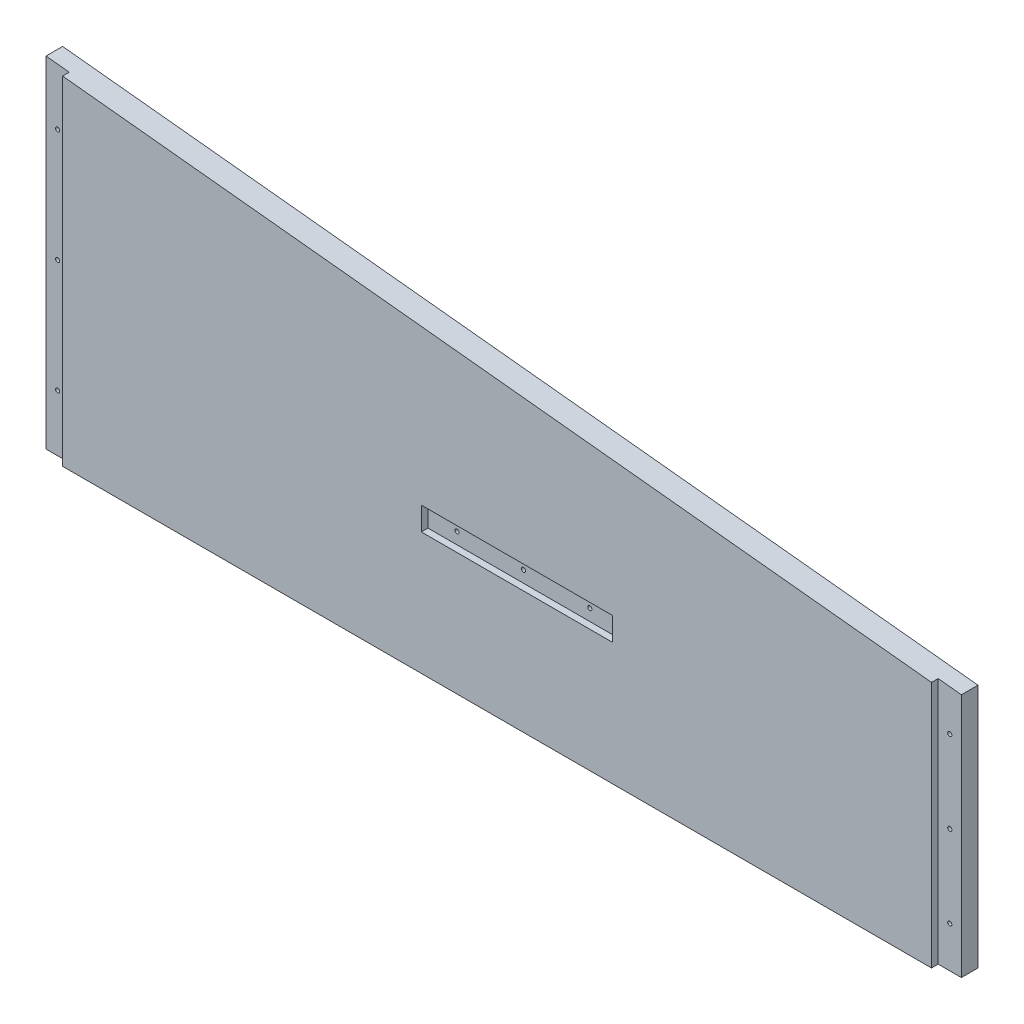
from build123d import *

# Parameters (mm, degrees)
EXTRUDE3_DEPTH     = 17.78
SKETCH8_R          = 1.5875
CUT_EXTRUDE4_DEPTH = 17.78
SKETCH9_W          = 17.78
SKETCH9_H          = 260.35
SKETCH9_H_2        = 189.179603175
SKETCH9_W_2        = 146.050000002
SKETCH9_H_3        = 17.78
CUT_EXTRUDE5_DEPTH = 5.08


with BuildPart() as part:
    # Sketch7 → Extrude3 (new body)
    with BuildSketch(Plane.XY):
        Polygon((157.1625, -6013.45), (857.25, -6013.45), (857.25, -5826.125), (157.1625, -5753.1), align=None)
    extrude(amount=-EXTRUDE3_DEPTH)

    # Sketch8 → Cut-Extrude4 (cut)
    with BuildSketch(Plane.XY):
        with Locations((166.0525, -5970.212883599)):
            Circle(SKETCH8_R)
        with Locations((166.0525, -5883.738650795)):
            Circle(SKETCH8_R)
        with Locations((166.0525, -5797.264417991)):
            Circle(SKETCH8_R)
        with Locations((848.36, -5982.074616401)):
            Circle(SKETCH8_R)
        with Locations((848.36, -5919.323849205)):
            Circle(SKETCH8_R)
        with Locations((848.36, -5856.573082009)):
            Circle(SKETCH8_R)
        with Locations((471.4875, -5910.834)):
            Circle(SKETCH8_R)
        with Locations((522.2875, -5910.834)):
            Circle(SKETCH8_R)
        with Locations((573.0875, -5910.834)):
            Circle(SKETCH8_R)
    extrude(amount=-CUT_EXTRUDE4_DEPTH, mode=Mode.SUBTRACT)

    # Sketch9 → Cut-Extrude5 (cut)
    with BuildSketch(Plane.XY):
        with Locations((166.0525, -5883.275)):
            Rectangle(SKETCH9_W, SKETCH9_H)
        with Locations((848.36, -5918.860198413)):
            Rectangle(SKETCH9_W, SKETCH9_H_2)
        with Locations((522.2875, -5910.834)):
            Rectangle(SKETCH9_W_2, SKETCH9_H_3)
    extrude(amount=-CUT_EXTRUDE5_DEPTH, mode=Mode.SUBTRACT)


solid = part.part
